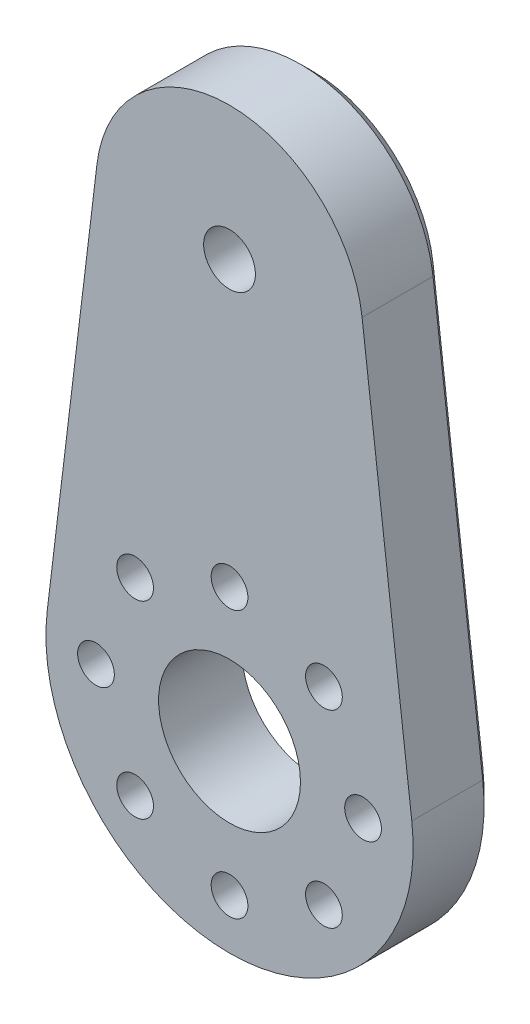
from build123d import *

# Parameters (mm, degrees)
SKETCH1_R           = 1.55
SKETCH1_R_2         = 4.25
SKETCH1_R_3         = 1.1
BOSS_EXTRUDE1_DEPTH = 5
CUT_EXTRUDE2_DEPTH  = 2
SKETCH4_R           = 1.75
CUT_EXTRUDE3_DEPTH  = 2.25
CHAFL_N1_SIZE       = 0.75


with BuildPart() as part:
    # Sketch1 → Boss-Extrude1 (new body)
    with BuildSketch(Plane.XY):
        with BuildLine():
            Line((-23.020815218, 6.216096398), (-25.999136894, -18.423903602))
            ThreePointArc((-25.999136894, -18.423903602), (-15.078624085, -30.743903602), (-4.158111277, -18.423903602))
            Line((-4.158111277, -18.423903602), (-7.136432952, 6.216096398))
            ThreePointArc((-7.136432952, 6.216096398), (-15.078624085, 13.256096398), (-23.020815218, 6.216096398))
        make_face()
        with Locations((-15.078624085, 5.256096398)):
            Circle(SKETCH1_R, mode=Mode.SUBTRACT)
        with Locations((-15.078624085, -19.743903602)):
            Circle(SKETCH1_R_2, mode=Mode.SUBTRACT)
        with Locations((-7.078624085, -19.743903602)):
            Circle(SKETCH1_R_3, mode=Mode.SUBTRACT)
        with Locations((-9.421769836, -25.400757851)):
            Circle(SKETCH1_R_3, mode=Mode.SUBTRACT)
        with Locations((-15.078624085, -27.743903602)):
            Circle(SKETCH1_R_3, mode=Mode.SUBTRACT)
        with Locations((-20.735478335, -25.400757851)):
            Circle(SKETCH1_R_3, mode=Mode.SUBTRACT)
        with Locations((-23.078624085, -19.743903602)):
            Circle(SKETCH1_R_3, mode=Mode.SUBTRACT)
        with Locations((-20.735478335, -14.087049352)):
            Circle(SKETCH1_R_3, mode=Mode.SUBTRACT)
        with Locations((-15.078624085, -11.743903602)):
            Circle(SKETCH1_R_3, mode=Mode.SUBTRACT)
        with Locations((-9.421769836, -14.087049352)):
            Circle(SKETCH1_R_3, mode=Mode.SUBTRACT)
    extrude(amount=BOSS_EXTRUDE1_DEPTH)

    # Sketch3 → Cut-Extrude2 (cut)
    with BuildSketch(Plane.XY):
        Polygon((-13.490910845, 2.506096398), (-11.903197604, 5.256096398), (-13.490910845, 8.006096398), (-16.666337325, 8.006096398), (-18.254050566, 5.256096398), (-16.666337325, 2.506096398), align=None)
    extrude(amount=CUT_EXTRUDE2_DEPTH, mode=Mode.SUBTRACT)

    # Sketch4 → Cut-Extrude3 (cut)
    with BuildSketch(Plane(origin=(0, 0, 0), x_dir=(-1, 0, 0), z_dir=(0, 0, -1))):
        with Locations((23.078624085, -19.743903602)):
            Circle(SKETCH4_R)
        with Locations((20.735478335, -25.400757851)):
            Circle(SKETCH4_R)
        with Locations((15.078624085, -27.743903602)):
            Circle(SKETCH4_R)
        with Locations((9.421769836, -25.400757851)):
            Circle(SKETCH4_R)
        with Locations((7.078624085, -19.743903602)):
            Circle(SKETCH4_R)
        with Locations((9.421769836, -14.087049352)):
            Circle(SKETCH4_R)
        with Locations((15.078624085, -11.743903602)):
            Circle(SKETCH4_R)
        with Locations((20.735478335, -14.087049352)):
            Circle(SKETCH4_R)
    extrude(amount=-CUT_EXTRUDE3_DEPTH, mode=Mode.SUBTRACT)

    # Chaflán1
    chafl_n1_edges = [part.edges().sort_by_distance(p)[0] for p in [
        (-5.647272114, -6.103903602, 0),
        (-15.078624085, -30.743903602, 0),
        (-24.509976056, -6.103903602, 0),
        (-15.078624085, 13.256096398, 0),
    ]]
    chamfer(chafl_n1_edges, length=CHAFL_N1_SIZE)


solid = part.part
